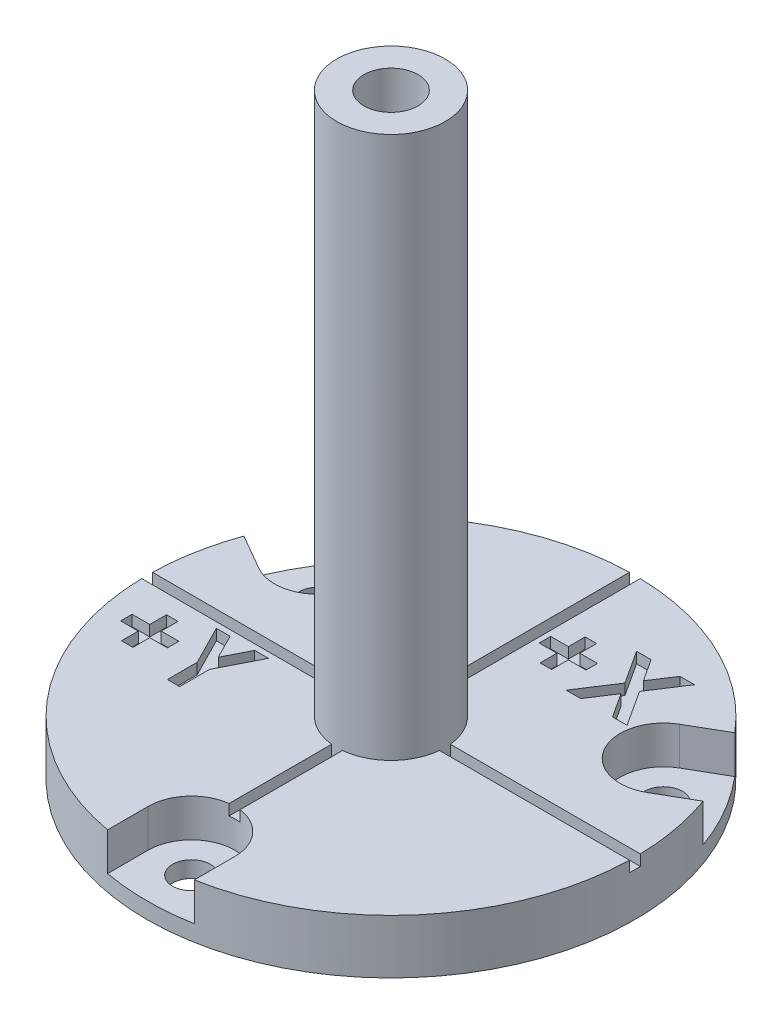
from build123d import *

# Parameters (mm, degrees)
SKETCH1_R                = 22.5
PLATE_DEPTH              = 5
OPENING_START            = 1.5
OPENING_FOR_SCREW_DEPTH  = 5
SKETCH7_R                = 1.75
SCREW_HOLE_DEPTH         = 5
CIRPATTERN20_COUNT       = 3
SKETCH10_W               = 45
SKETCH10_H               = 1
SKETCH10_W_2             = 1
SKETCH10_H_2             = 45
CUT_EXTRUDE5_DEPTH       = 1
CUT_EXTRUDE6_DEPTH       = 1
SKETCH12_R               = 5
SKETCH12_R_2             = 2.5
BOSS_EXTRUDE2_DEPTH      = 50
BOSS_EXTRUDE2_DEPTH_BACK = 1


with BuildPart() as part:
    # Sketch1 → plate (new body)
    with BuildSketch(Plane(origin=(0, 0, 0), x_dir=(1, 0, 0), z_dir=(0, 1, 0))):
        Circle(SKETCH1_R)
    extrude(amount=PLATE_DEPTH)

    # Sketch6 → opening for screw (cut)
    with BuildSketch(Plane(origin=(0, 5, 0), x_dir=(1, 0, 0), z_dir=(0, 1, 0)).offset(OPENING_START)):
        with BuildLine():
            Line((-4, -22.5), (-4, -18.4))
            ThreePointArc((-4, -18.4), (0, -14.4), (4, -18.4))
            Line((4, -18.4), (4, -22.5))
            ThreePointArc((4, -22.5), (0, -26.5), (-4, -22.5))
        make_face()
    opening_for_screw = extrude(amount=-OPENING_FOR_SCREW_DEPTH, mode=Mode.SUBTRACT)

    # Sketch7 → screw hole (cut)
    with BuildSketch(Plane(origin=(0, 1.5, 0), x_dir=(1, 0, 0), z_dir=(0, 1, 0))):
        with Locations((0, -18.4)):
            Circle(SKETCH7_R)
    screw_hole = extrude(amount=-SCREW_HOLE_DEPTH, mode=Mode.SUBTRACT)

    # CirPattern20: opening for screw, screw hole ×3 about axis
    cirpattern20_axis = Axis((0, 0, 0), (0, 1, 0))
    for i in range(1, CIRPATTERN20_COUNT):
        add(opening_for_screw.rotate(cirpattern20_axis, i * 360 / CIRPATTERN20_COUNT), mode=Mode.SUBTRACT)
        add(screw_hole.rotate(cirpattern20_axis, i * 360 / CIRPATTERN20_COUNT), mode=Mode.SUBTRACT)

    # Sketch10 → Cut-Extrude5 (cut)
    with BuildSketch(Plane(origin=(0, 5, 0), x_dir=(1, 0, 0), z_dir=(0, 1, 0))):
        Rectangle(SKETCH10_W, SKETCH10_H)
        Rectangle(SKETCH10_W_2, SKETCH10_H_2)
    extrude(amount=-CUT_EXTRUDE5_DEPTH, mode=Mode.SUBTRACT)

    # Sketch11 → Cut-Extrude6 (cut)
    with BuildSketch(Plane(origin=(0, 5, 0), x_dir=(1, 0, 0), z_dir=(0, 1, 0))):
        Polygon((2.616666667, 13.742425761), (2.616666667, 15.289220632), (3.675, 15.289220632), (3.675, 13.742425761), (5.303205128, 13.742425761), (5.303205128, 12.684092427), (3.675, 12.684092427), (3.675, 11.137297556), (2.616666667, 11.137297556), (2.616666667, 12.684092427), (0.988461538, 12.684092427), (0.988461538, 13.742425761), align=None)
        Polygon((6.136388221, 16.510374479), (7.479657452, 16.510374479), (8.806390224, 14.471301963), (10.135667067, 16.510374479), (11.480208333, 16.510374479), (9.47802484, 13.43968137), (11.6125, 10.160374479), (10.269230769, 10.160374479), (8.806390224, 12.409332812), (7.339733574, 10.160374479), (5.995192308, 10.160374479), (8.134755609, 13.440953405), align=None)
        Polygon((-18.458103671, -3.794817635), (-18.458103671, -2.248022763), (-17.399770338, -2.248022763), (-17.399770338, -3.794817635), (-15.771565209, -3.794817635), (-15.771565209, -4.853150968), (-17.399770338, -4.853150968), (-17.399770338, -6.39994584), (-18.458103671, -6.39994584), (-18.458103671, -4.853150968), (-20.086308799, -4.853150968), (-20.086308799, -3.794817635), align=None)
        Polygon((-15.07957803, -1.026868917), (-13.811358879, -1.026868917), (-12.677975466, -3.254202651), (-11.544592052, -1.026868917), (-10.276372902, -1.026868917), (-12.108103671, -4.626728693), (-12.108103671, -7.376868917), (-13.247847261, -7.376868917), (-13.247847261, -4.626728693), align=None)
    extrude(amount=-CUT_EXTRUDE6_DEPTH, mode=Mode.SUBTRACT)

    # Sketch12 → Boss-Extrude2 (add, two sides)
    with BuildSketch(Plane(origin=(0, 5, 0), x_dir=(1, 0, 0), z_dir=(0, 1, 0))) as boss_extrude2_sk:
        Circle(SKETCH12_R)
        Circle(SKETCH12_R_2, mode=Mode.SUBTRACT)
    extrude(amount=BOSS_EXTRUDE2_DEPTH)
    extrude(boss_extrude2_sk.sketch, amount=-BOSS_EXTRUDE2_DEPTH_BACK)


solid = part.part
